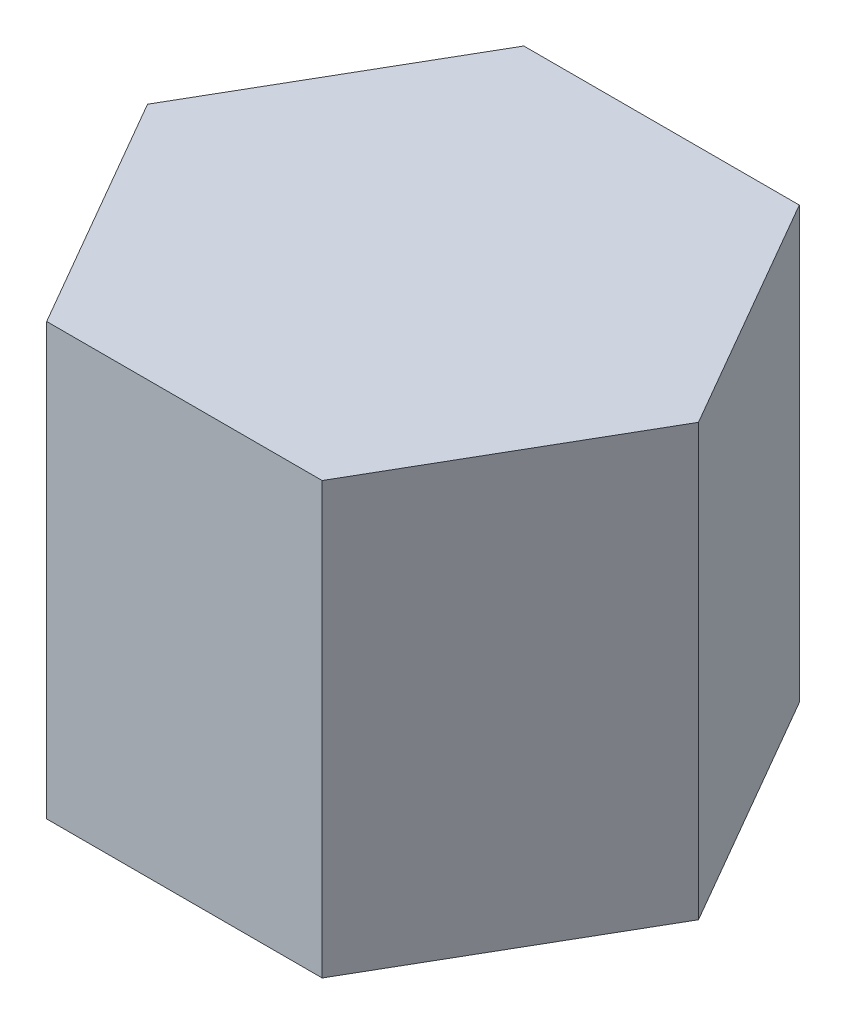
from build123d import *

# Parameters (mm, degrees)
BOSS_EXTRUDE1_DEPTH = 80


with BuildPart() as part:
    # Sketch1 → Boss-Extrude1 (new body)
    with BuildSketch(Plane(origin=(0, 0, 0), x_dir=(1, 0, 0), z_dir=(0, 1, 0))):
        Polygon((25.576616925, -44.3), (51.15323385, 0), (25.576616925, 44.3), (-25.576616925, 44.3), (-51.15323385, 0), (-25.576616925, -44.3), align=None)
    extrude(amount=-BOSS_EXTRUDE1_DEPTH)


solid = part.part
